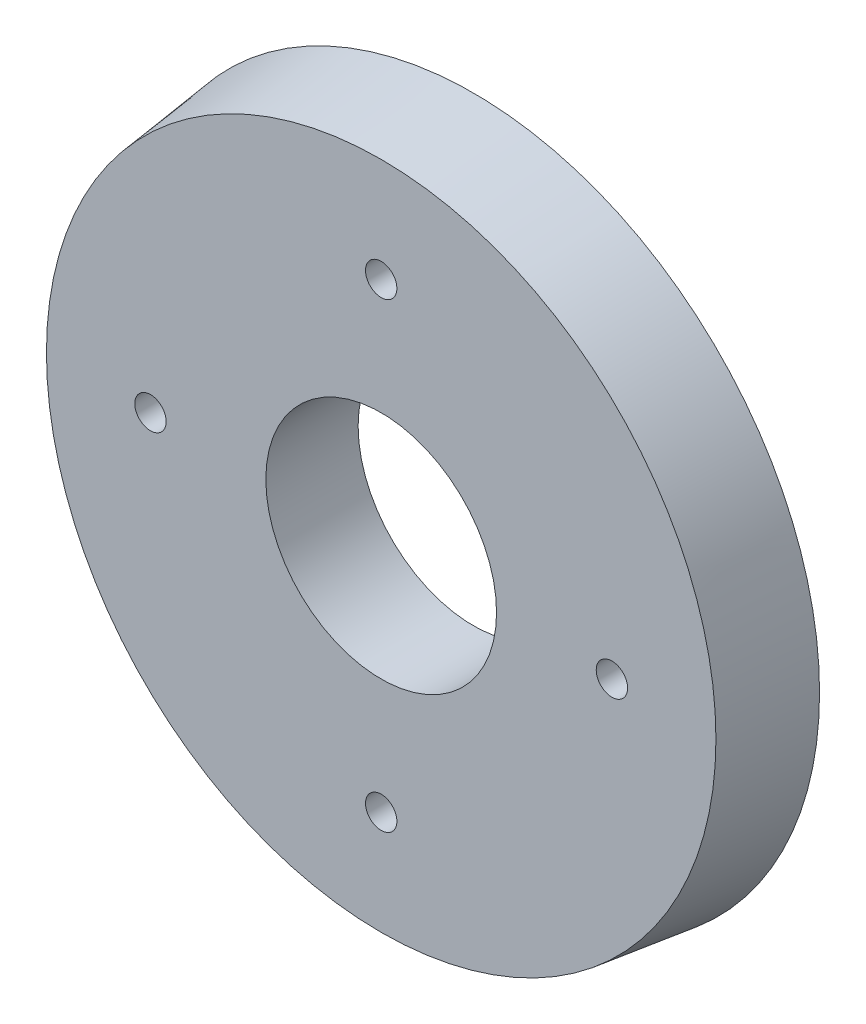
from build123d import *

# Parameters (mm, degrees)
SKETCH1_R           = 75
BOSS_EXTRUDE1_DEPTH = 20
BOSS_EXTRUDE1_TAPER = 7
SKETCH6_R           = 25
SKETCH6_R_2         = 3.4
CUT_EXTRUDE1_DEPTH  = 21


with BuildPart() as part:
    # Sketch1 → Boss-Extrude1 (new body)
    with BuildSketch(Plane.XY):
        Circle(SKETCH1_R)
    extrude(amount=BOSS_EXTRUDE1_DEPTH, taper=BOSS_EXTRUDE1_TAPER)

    # Sketch6 → Cut-Extrude1 (cut, through all)
    with BuildSketch(Plane(origin=(0, 0, 0), x_dir=(-1, 0, 0), z_dir=(0, 0, -1))):
        Circle(SKETCH6_R)
        with Locations((0, 50)):
            Circle(SKETCH6_R_2)
        with Locations((50, 0)):
            Circle(SKETCH6_R_2)
        with Locations((0, -50)):
            Circle(SKETCH6_R_2)
        with Locations((-50, 0)):
            Circle(SKETCH6_R_2)
    extrude(amount=-CUT_EXTRUDE1_DEPTH, mode=Mode.SUBTRACT)


solid = part.part
